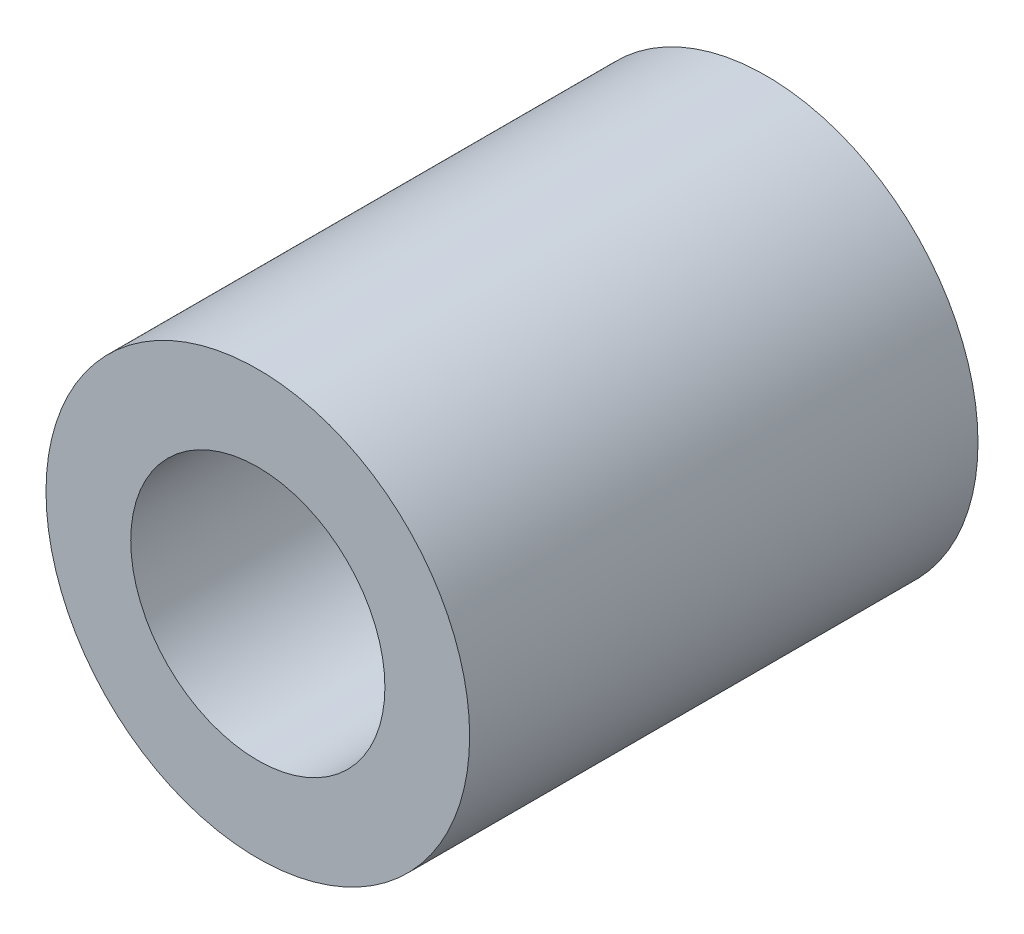
from build123d import *

# Parameters (mm, degrees)
ESBO_O1_R                = 5
ESBO_O1_R_2              = 3
RESSALTO_EXTRUS_O1_DEPTH = 12


with BuildPart() as part:
    # Esboço1 → Ressalto-extrusão1 (new body)
    with BuildSketch(Plane.XY):
        Circle(ESBO_O1_R)
        Circle(ESBO_O1_R_2, mode=Mode.SUBTRACT)
    extrude(amount=RESSALTO_EXTRUS_O1_DEPTH)


solid = part.part
